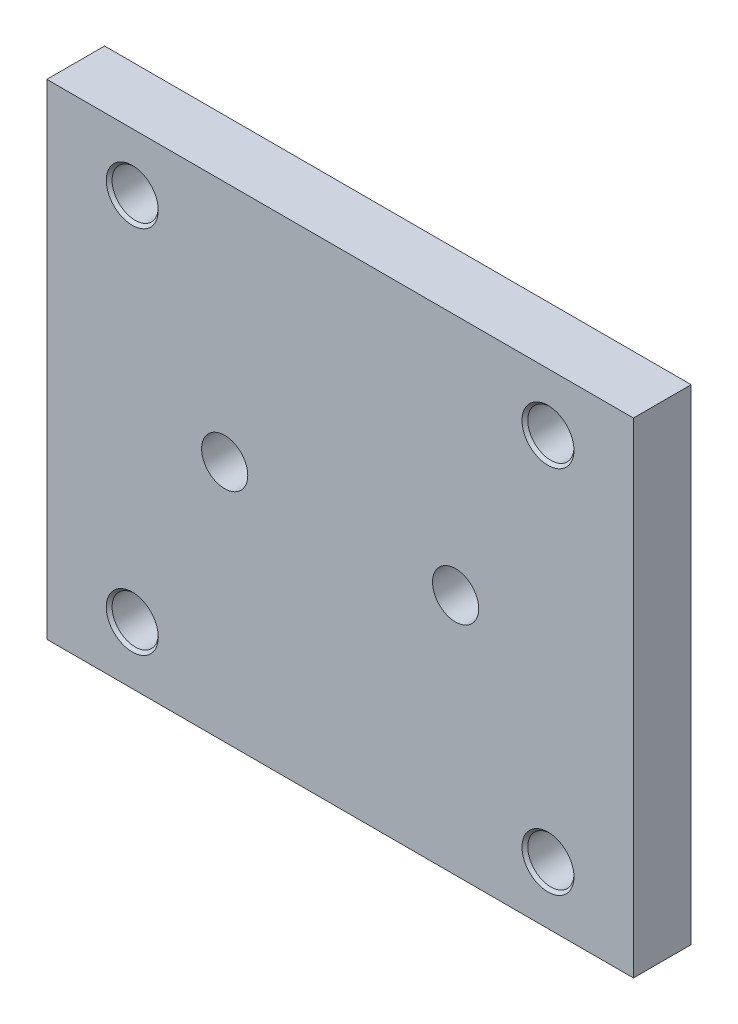
from build123d import *

# Parameters (mm, degrees)
SKETCH1_W           = 254
SKETCH1_H           = 210
SKETCH1_R           = 10
BOSS_EXTRUDE1_DEPTH = 25
CUT_EXTRUDE1_REACH  = 168.67
SKETCH2_R           = 10


with BuildPart() as part:
    # Sketch1 → Boss-Extrude1 (new body)
    with BuildSketch(Plane.XY):
        Rectangle(SKETCH1_W, SKETCH1_H)
        with Locations((-90, 80)):
            Circle(SKETCH1_R, mode=Mode.SUBTRACT)
        with Locations((90, 80)):
            Circle(SKETCH1_R, mode=Mode.SUBTRACT)
        with Locations((90, -80)):
            Circle(SKETCH1_R, mode=Mode.SUBTRACT)
        with Locations((-90, -80)):
            Circle(SKETCH1_R, mode=Mode.SUBTRACT)
    extrude(amount=BOSS_EXTRUDE1_DEPTH)

    # Sketch2 → Cut-Extrude1 (cut, up to next)
    with BuildSketch(Plane.XY.offset(25), mode=Mode.PRIVATE) as cut_extrude1_sk1:
        with Locations((-50, 0)):
            Circle(SKETCH2_R)
    cut_extrude1_tool1 = extrude(cut_extrude1_sk1.sketch, amount=-CUT_EXTRUDE1_REACH, mode=Mode.PRIVATE) & part.part
    # Sketch2 → Cut-Extrude1 (cut, up to next)
    with BuildSketch(Plane.XY.offset(25), mode=Mode.PRIVATE) as cut_extrude1_sk2:
        with Locations((50, 0)):
            Circle(SKETCH2_R)
    cut_extrude1_tool2 = extrude(cut_extrude1_sk2.sketch, amount=-CUT_EXTRUDE1_REACH, mode=Mode.PRIVATE) & part.part
    add(cut_extrude1_tool1.solids().sort_by_distance((-50, 0, 25))[0], mode=Mode.SUBTRACT)
    add(cut_extrude1_tool2.solids().sort_by_distance((50, 0, 25))[0], mode=Mode.SUBTRACT)

    # Cut-Extrude2 cone 1 section (through the dimple's axis) → Cut-Extrude2 (revolve, cut)
    with BuildSketch(Plane(origin=(-90, 80, 25), x_dir=(0, -1, 0), z_dir=(1, 0, 0))):
        Polygon((0, 0), (11.25, 0), (0, 11.25), align=None)
    revolve(axis=Axis((-90, 80, 25), (0, 0, -1)), mode=Mode.SUBTRACT)

    # Cut-Extrude2 cone 2 section (through the dimple's axis) → Cut-Extrude2 cone 2 (revolve, cut)
    with BuildSketch(Plane(origin=(90, 80, 25), x_dir=(0, -1, 0), z_dir=(1, 0, 0))):
        Polygon((0, 0), (11.25, 0), (0, 11.25), align=None)
    revolve(axis=Axis((90, 80, 25), (0, 0, -1)), mode=Mode.SUBTRACT)

    # Cut-Extrude2 cone 3 section (through the dimple's axis) → Cut-Extrude2 cone 3 (revolve, cut)
    with BuildSketch(Plane(origin=(90, -80, 25), x_dir=(0, -1, 0), z_dir=(1, 0, 0))):
        Polygon((0, 0), (11.25, 0), (0, 11.25), align=None)
    revolve(axis=Axis((90, -80, 25), (0, 0, -1)), mode=Mode.SUBTRACT)

    # Cut-Extrude2 cone 4 section (through the dimple's axis) → Cut-Extrude2 cone 4 (revolve, cut)
    with BuildSketch(Plane(origin=(-90, -80, 25), x_dir=(0, -1, 0), z_dir=(1, 0, 0))):
        Polygon((0, 0), (11.25, 0), (0, 11.25), align=None)
    revolve(axis=Axis((-90, -80, 25), (0, 0, -1)), mode=Mode.SUBTRACT)


solid = part.part
